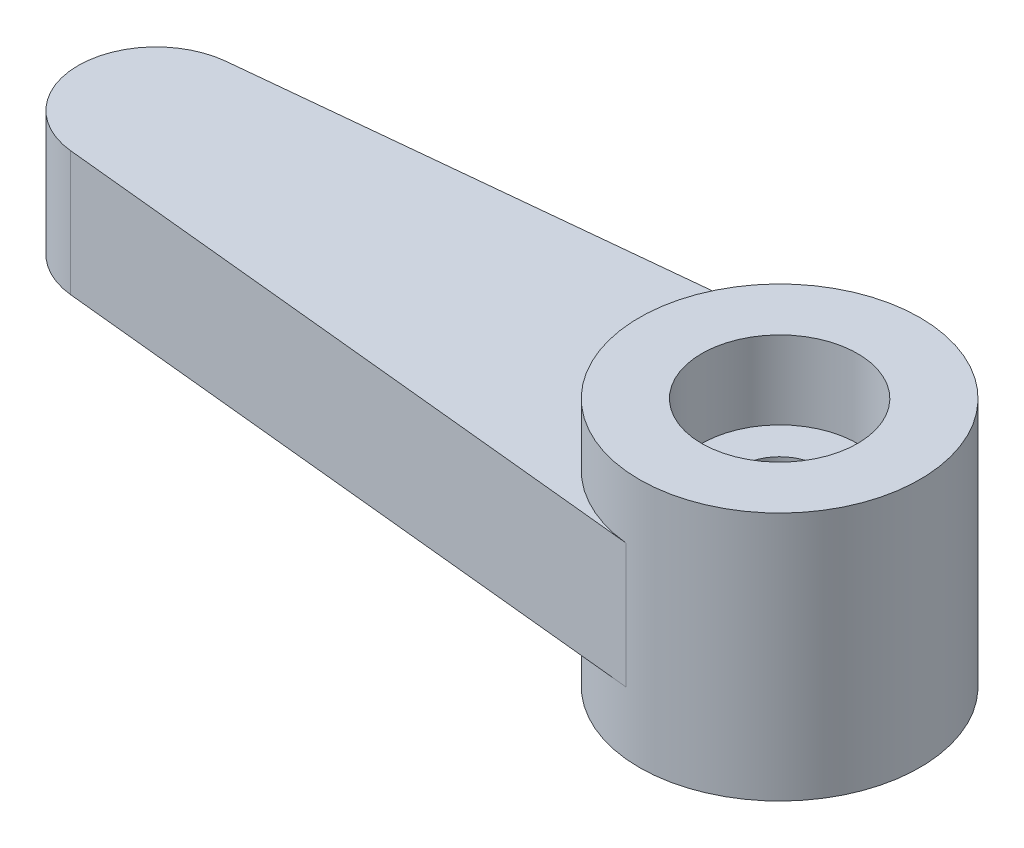
from build123d import *

# Parameters (mm, degrees)
SALIENTE_EXTRUIR1_DEPTH      = 2
SALIENTE_EXTRUIR1_DEPTH_BACK = 2


with BuildPart() as part:
    # Croquis1 → Revolución1 (revolve)
    with BuildSketch(Plane(origin=(0, 0, 0), x_dir=(0, 0, -1), z_dir=(1, 0, 0))):
        Polygon((-4.5, 4), (-4.5, -4), (-2.158881548, -4), (-2.158881548, -1.5), (-1.25, -1.5), (-1.25, 1.5), (-2.5, 1.5), (-2.5, 4), align=None)
    revolve(axis=Axis((0, 9.054619894, 0), (0, -1, 0)))

    # Croquis2 → Saliente-Extruir1 (add, two sides)
    with BuildSketch(Plane(origin=(0, 0, 0), x_dir=(1, 0, 0), z_dir=(0, 1, 0))) as saliente_extruir1_sk:
        with BuildLine():
            Line((-20.25, 2.487468593), (-0.45, 4.477443467))
            ThreePointArc((-0.45, 4.477443467), (-4.5, 0), (-0.45, -4.477443467))
            Line((-0.45, -4.477443467), (-20.25, -2.487468593))
            ThreePointArc((-20.25, -2.487468593), (-22.5, 0), (-20.25, 2.487468593))
        make_face()
    extrude(amount=SALIENTE_EXTRUIR1_DEPTH)
    extrude(saliente_extruir1_sk.sketch, amount=-SALIENTE_EXTRUIR1_DEPTH_BACK)


solid = part.part
